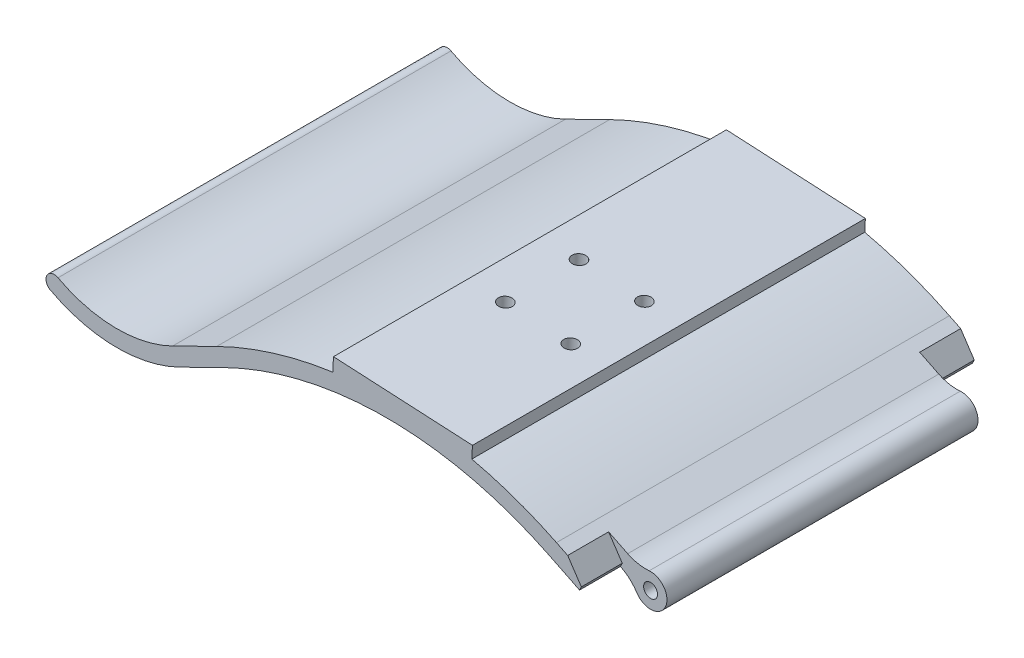
from build123d import *

# Parameters (mm, degrees)
CROQUIS1_R                   = 1.7
SALIENTE_EXTRUIR1_DEPTH      = 48
REDONDEO1_R                  = 10
CORTAR_EXTRUIR1_DEPTH        = 10
CHAFL_N1_SIZE                = 3
CHAFL_N1_SIZE2               = 5.196152423
CHAFL_N1_PART_2_SIZE         = 3
CHAFL_N1_PART_2_SIZE2        = 5.196152423
SALIENTE_EXTRUIR2_DEPTH      = 48
SALIENTE_EXTRUIR2_DEPTH_BACK = 48
CORTAR_EXTRUIR3_REACH        = 30.364
CROQUIS6_R                   = 1.7
CORTAR_EXTRUIR4_REACH        = 27.364


with BuildPart() as part:
    # Croquis1 → Saliente-Extruir1 (new body, symmetric)
    with BuildSketch(Plane.XY):
        with BuildLine():
            Line((-39.737417582, -9.247677161), (-50.50439396, -14.545999505))
            ThreePointArc((-50.50439396, -14.545999505), (-66.386844231, -18.110333527), (-82.148948738, -14.04674335))
            ThreePointArc((-82.148948738, -14.04674335), (-82.975471065, -11.341773693), (-80.270501408, -10.515251366))
            ThreePointArc((-80.270501408, -10.515251366), (-66.323744082, -14.110831262), (-52.270501408, -10.957007379))
            Line((-52.270501408, -10.957007379), (-41.50352503, -5.658685035))
            ThreePointArc((-41.50352503, -5.658685035), (0, 4), (41.50352503, -5.658685035))
            Line((41.50352503, -5.658685035), (52.270501408, -10.957007379))
            ThreePointArc((52.270501408, -10.957007379), (58.084598166, -16.047104806), (50.50439396, -14.545999505))
            Line((50.50439396, -14.545999505), (39.737417582, -9.247677161))
            ThreePointArc((39.737417582, -9.247677161), (0, 0), (-39.737417582, -9.247677161))
        make_face()
        with Locations((54.49560604, -14.280997358)):
            Circle(CROQUIS1_R, mode=Mode.SUBTRACT)
    extrude(amount=SALIENTE_EXTRUIR1_DEPTH, both=True)

    # Redondeo1
    redondeo1_edges = [part.edges().sort_by_distance(p)[0] for p in [
        (52.270501408, -10.957007379, 0),
        (50.50439396, -14.545999505, 0),
    ]]
    fillet(redondeo1_edges, radius=REDONDEO1_R)

    # Croquis3 → Cortar-Extruir1 (cut)
    with BuildSketch(Plane.XY.offset(48)):
        with BuildLine():
            Line((48.908512195, -9.302605814), (47.142404747, -12.89159794))
            ThreePointArc((47.142404747, -12.89159794), (49.37979166, -14.398010057), (51.133186064, -16.4475919))
            ThreePointArc((51.133186064, -16.4475919), (58.084598166, -16.047104806), (54.160798833, -10.295033969))
            ThreePointArc((54.160798833, -10.295033969), (51.467117745, -10.156254046), (48.908512195, -9.302605814))
        make_face()
    cortar_extruir1 = extrude(amount=-CORTAR_EXTRUIR1_DEPTH, mode=Mode.SUBTRACT)

    # Simetría1: Cortar-Extruir1 across plane
    add(cortar_extruir1.mirror(Plane.XY), mode=Mode.SUBTRACT)

    # Chaflán1
    chafl_n1_edges = [part.edges().sort_by_distance(p)[0] for p in [
        (48.908512195, -9.302605814, 43),
    ]]
    chafl_n1_side = [part.faces().sort_by_distance(p)[0] for p in [
        (48.025458471, -11.097101877, 43),
    ]]
    chamfer(chafl_n1_edges, length=CHAFL_N1_SIZE, length2=CHAFL_N1_SIZE2, reference=chafl_n1_side[0])

    # Chaflán1 part 2
    chafl_n1_part_2_edges = [part.edges().sort_by_distance(p)[0] for p in [
        (48.908512195, -9.302605814, -43),
    ]]
    chafl_n1_part_2_side = [part.faces().sort_by_distance(p)[0] for p in [
        (48.025458471, -11.097101877, -43),
    ]]
    chamfer(chafl_n1_part_2_edges, length=CHAFL_N1_PART_2_SIZE, length2=CHAFL_N1_PART_2_SIZE2, reference=chafl_n1_part_2_side[0])

    # Croquis5 → Saliente-Extruir2 (add, two sides)
    with BuildSketch(Plane.XY) as saliente_extruir2_sk:
        with BuildLine():
            Line((-12.976702091, 6.440682618), (20.976702091, 4.661260106))
            Line((20.976702091, 4.661260106), (20.819694222, 1.665371501))
            ThreePointArc((20.819694222, 1.665371501), (3.897584771, 3.91916116), (-13.153078528, 3.075219716))
            Line((-13.153078528, 3.075219716), (-12.976702091, 6.440682618))
        make_face()
    extrude(amount=SALIENTE_EXTRUIR2_DEPTH)
    extrude(saliente_extruir2_sk.sketch, amount=-SALIENTE_EXTRUIR2_DEPTH_BACK)

    # Croquis6 → Cortar-Extruir3 (cut, up to next)
    with BuildSketch(Plane(origin=(0.301073462, 5.744823887, 0), x_dir=(0.998629535, -0.052335956, 0), z_dir=(0.052335956, 0.998629535, 0)), mode=Mode.PRIVATE) as cortar_extruir3_sk1:
        with Locations((-4.295997255, 3)):
            Circle(CROQUIS6_R)
    cortar_extruir3_tool1 = extrude(cortar_extruir3_sk1.sketch, amount=-CORTAR_EXTRUIR3_REACH, mode=Mode.PRIVATE) & part.part
    add(cortar_extruir3_tool1.solids().sort_by_distance((-3.989036, 5.969659, -3))[0], mode=Mode.SUBTRACT)
    # Croquis6 → Cortar-Extruir3 (cut, up to next)
    with BuildSketch(Plane(origin=(0.301073462, 5.744823887, 0), x_dir=(0.998629535, -0.052335956, 0), z_dir=(0.052335956, 0.998629535, 0)), mode=Mode.PRIVATE) as cortar_extruir3_sk2:
        with Locations((11.704002745, 3)):
            Circle(CROQUIS6_R)
    cortar_extruir3_tool2 = extrude(cortar_extruir3_sk2.sketch, amount=-CORTAR_EXTRUIR3_REACH, mode=Mode.PRIVATE) & part.part
    add(cortar_extruir3_tool2.solids().sort_by_distance((11.989036, 5.132284, -3))[0], mode=Mode.SUBTRACT)
    # Croquis6 → Cortar-Extruir3 (cut, up to next)
    with BuildSketch(Plane(origin=(0.301073462, 5.744823887, 0), x_dir=(0.998629535, -0.052335956, 0), z_dir=(0.052335956, 0.998629535, 0)), mode=Mode.PRIVATE) as cortar_extruir3_sk3:
        with Locations((11.704002745, -15)):
            Circle(CROQUIS6_R)
    cortar_extruir3_tool3 = extrude(cortar_extruir3_sk3.sketch, amount=-CORTAR_EXTRUIR3_REACH, mode=Mode.PRIVATE) & part.part
    add(cortar_extruir3_tool3.solids().sort_by_distance((11.989036, 5.132284, 15))[0], mode=Mode.SUBTRACT)
    # Croquis6 → Cortar-Extruir3 (cut, up to next)
    with BuildSketch(Plane(origin=(0.301073462, 5.744823887, 0), x_dir=(0.998629535, -0.052335956, 0), z_dir=(0.052335956, 0.998629535, 0)), mode=Mode.PRIVATE) as cortar_extruir3_sk4:
        with Locations((-4.295997255, -15)):
            Circle(CROQUIS6_R)
    cortar_extruir3_tool4 = extrude(cortar_extruir3_sk4.sketch, amount=-CORTAR_EXTRUIR3_REACH, mode=Mode.PRIVATE) & part.part
    add(cortar_extruir3_tool4.solids().sort_by_distance((-3.989036, 5.969659, 15))[0], mode=Mode.SUBTRACT)

    # Croquis7 → Cortar-Extruir4 (cut, up to next)
    with BuildSketch(Plane(origin=(0.144065594, 2.748935283, 0), x_dir=(0.998629535, -0.052335956, 0), z_dir=(0.052335956, 0.998629535, 0)), mode=Mode.PRIVATE) as cortar_extruir4_sk1:
        Polygon((-0.889630667, 3), (-2.592813961, 5.95), (-5.999180549, 5.95), (-7.702363843, 3), (-5.999180549, 0.05), (-2.592813961, 0.05), align=None)
    cortar_extruir4_tool1 = extrude(cortar_extruir4_sk1.sketch, amount=-CORTAR_EXTRUIR4_REACH, mode=Mode.PRIVATE) & part.part
    add(cortar_extruir4_tool1.solids().sort_by_distance((-4.146044, 2.97377, -3))[0], mode=Mode.SUBTRACT)
    # Croquis7 → Cortar-Extruir4 (cut, up to next)
    with BuildSketch(Plane(origin=(0.144065594, 2.748935283, 0), x_dir=(0.998629535, -0.052335956, 0), z_dir=(0.052335956, 0.998629535, 0)), mode=Mode.PRIVATE) as cortar_extruir4_sk2:
        Polygon((15.110369333, 3), (13.407186039, 5.95), (10.000819451, 5.95), (8.297636157, 3), (10.000819451, 0.05), (13.407186039, 0.05), align=None)
    cortar_extruir4_tool2 = extrude(cortar_extruir4_sk2.sketch, amount=-CORTAR_EXTRUIR4_REACH, mode=Mode.PRIVATE) & part.part
    add(cortar_extruir4_tool2.solids().sort_by_distance((11.832028, 2.136395, -3))[0], mode=Mode.SUBTRACT)
    # Croquis7 → Cortar-Extruir4 (cut, up to next)
    with BuildSketch(Plane(origin=(0.144065594, 2.748935283, 0), x_dir=(0.998629535, -0.052335956, 0), z_dir=(0.052335956, 0.998629535, 0)), mode=Mode.PRIVATE) as cortar_extruir4_sk3:
        Polygon((-0.889630667, -15), (-2.592813961, -12.05), (-5.999180549, -12.05), (-7.702363843, -15), (-5.999180549, -17.95), (-2.592813961, -17.95), align=None)
    cortar_extruir4_tool3 = extrude(cortar_extruir4_sk3.sketch, amount=-CORTAR_EXTRUIR4_REACH, mode=Mode.PRIVATE) & part.part
    add(cortar_extruir4_tool3.solids().sort_by_distance((-4.146044, 2.97377, 15))[0], mode=Mode.SUBTRACT)
    # Croquis7 → Cortar-Extruir4 (cut, up to next)
    with BuildSketch(Plane(origin=(0.144065594, 2.748935283, 0), x_dir=(0.998629535, -0.052335956, 0), z_dir=(0.052335956, 0.998629535, 0)), mode=Mode.PRIVATE) as cortar_extruir4_sk4:
        Polygon((15.110369333, -15), (13.407186039, -12.05), (10.000819451, -12.05), (8.297636157, -15), (10.000819451, -17.95), (13.407186039, -17.95), align=None)
    cortar_extruir4_tool4 = extrude(cortar_extruir4_sk4.sketch, amount=-CORTAR_EXTRUIR4_REACH, mode=Mode.PRIVATE) & part.part
    add(cortar_extruir4_tool4.solids().sort_by_distance((11.832028, 2.136395, 15))[0], mode=Mode.SUBTRACT)


solid = part.part
